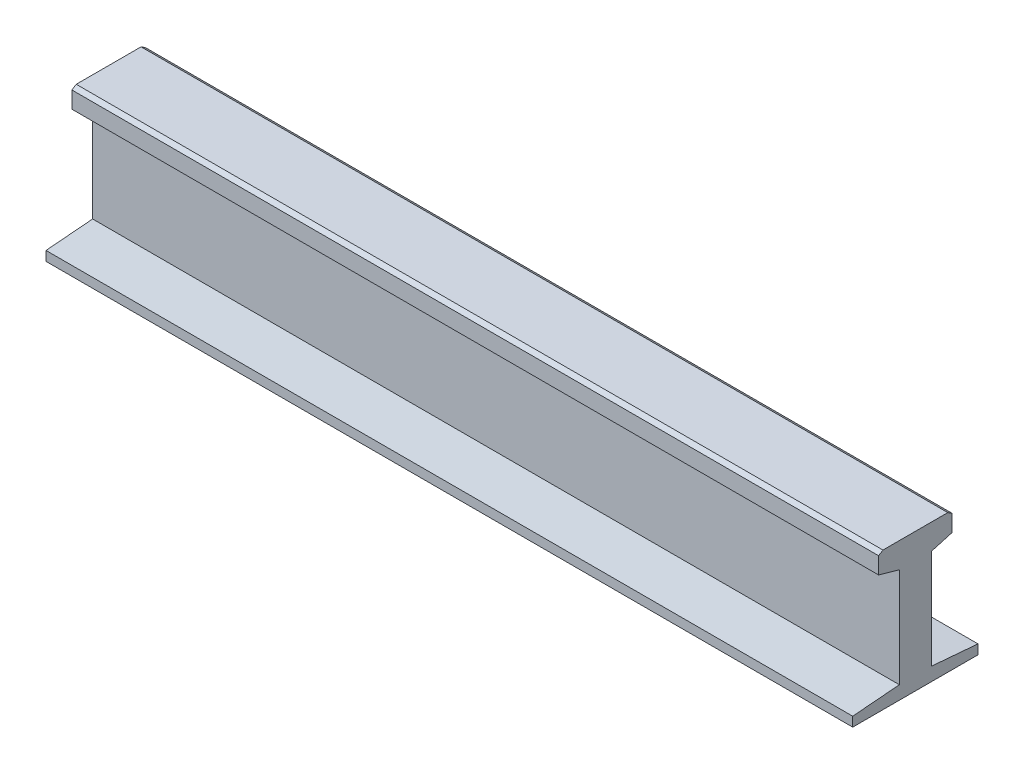
from build123d import *

# Parameters (mm, degrees)
EXTRUDE_1_DEPTH = 850


with BuildPart() as part:
    # Эскиз1 → Бобышка-Вытянуть1 (new body)
    with BuildSketch(Plane(origin=(0, 0, 0), x_dir=(0, 0, -1), z_dir=(1, 0, 0))):
        Polygon((-66, 0), (66, 0), (66, 10), (16.883336969, 14.163502235), (16.883336969, 118.984443331), (38.704461372, 125.219050303), (38.704461372, 142.782419329), (34.150995328, 145.7096475), (-34.150995328, 145.7096475), (-38.704461372, 142.782419329), (-38.704461372, 125.219050303), (-16.883336969, 118.984443331), (-16.883336969, 14.163502235), (-66, 10), align=None)
    extrude(amount=EXTRUDE_1_DEPTH)


solid = part.part
